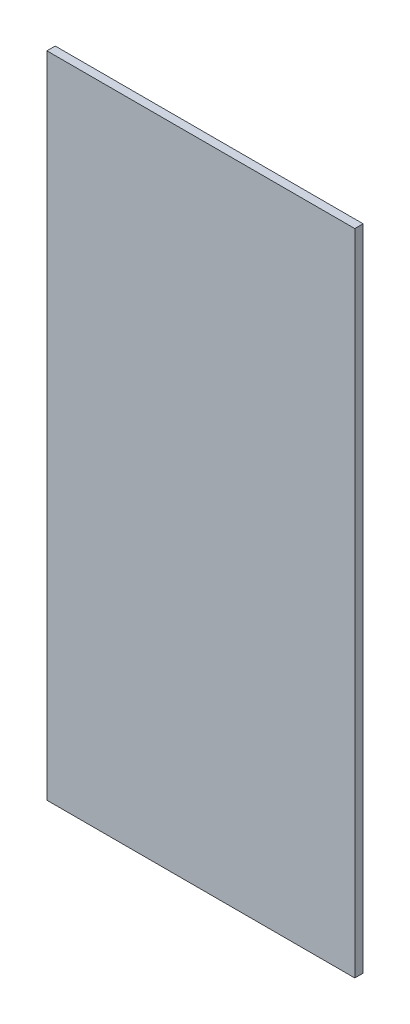
from build123d import *

# Parameters (mm, degrees)
CROQUIS2_W              = 234.95
CROQUIS2_H              = 6.35
SALIENTE_EXTRUIR1_DEPTH = 495.3


with BuildPart() as part:
    # Croquis2 → Saliente-Extruir1 (new body)
    with BuildSketch(Plane(origin=(0, 0, 0), x_dir=(1, 0, 0), z_dir=(0, 1, 0))):
        Rectangle(CROQUIS2_W, CROQUIS2_H)
    extrude(amount=SALIENTE_EXTRUIR1_DEPTH)


solid = part.part
